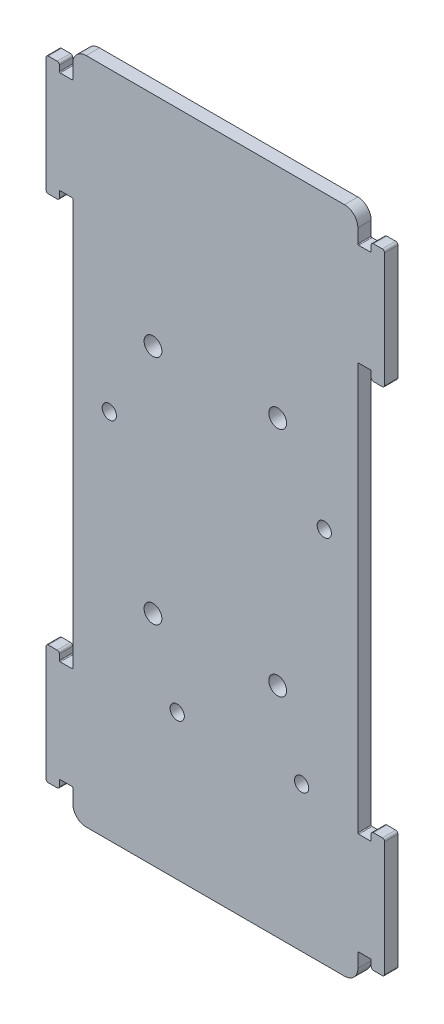
from build123d import *

# Parameters (mm, degrees)
EXTRUDE_1_DEPTH     = 1.5
CUT_EXTRUDE_1_REACH = 5
SKETCH_2_R          = 1.6
SKETCH_3_R          = 2
CUT_EXTRUDE_2_DEPTH = 10


with BuildPart() as part:
    # 草图1 → 凸台-拉伸1 (new body, symmetric)
    with BuildSketch(Plane.XY):
        with BuildLine():
            Line((32.2, 68.7), (34.8, 68.7))
            ThreePointArc((34.8, 68.7), (34.941421356, 68.758578644), (35, 68.9))
            Line((35, 68.9), (35, 70.15))
            ThreePointArc((35, 70.15), (35.146446609, 70.503553391), (35.5, 70.65))
            Line((35.5, 70.65), (37.5, 70.65))
            ThreePointArc((37.5, 70.65), (37.853553391, 70.503553391), (38, 70.15))
            Line((38, 70.15), (38, 44.35))
            ThreePointArc((38, 44.35), (37.853553391, 43.996446609), (37.5, 43.85))
            Line((37.5, 43.85), (35.5, 43.85))
            ThreePointArc((35.5, 43.85), (35.146446609, 43.996446609), (35, 44.35))
            Line((35, 44.35), (35, 45.6))
            ThreePointArc((35, 45.6), (34.941421356, 45.741421356), (34.8, 45.8))
            Line((34.8, 45.8), (32.2, 45.8))
            ThreePointArc((32.2, 45.8), (32.058578644, 45.741421356), (32, 45.6))
            Line((32, 45.6), (32, -45.6))
            ThreePointArc((32, -45.6), (32.058578644, -45.741421356), (32.2, -45.8))
            Line((32.2, -45.8), (34.8, -45.8))
            ThreePointArc((34.8, -45.8), (34.941421356, -45.741421356), (35, -45.6))
            Line((35, -45.6), (35, -44.35))
            ThreePointArc((35, -44.35), (35.146446609, -43.996446609), (35.5, -43.85))
            Line((35.5, -43.85), (37.5, -43.85))
            ThreePointArc((37.5, -43.85), (37.853553391, -43.996446609), (38, -44.35))
            Line((38, -44.35), (38, -70.15))
            ThreePointArc((38, -70.15), (37.853553391, -70.503553391), (37.5, -70.65))
            Line((37.5, -70.65), (35.5, -70.65))
            ThreePointArc((35.5, -70.65), (35.146446609, -70.503553391), (35, -70.15))
            Line((35, -70.15), (35, -68.9))
            ThreePointArc((35, -68.9), (34.941421356, -68.758578644), (34.8, -68.7))
            Line((34.8, -68.7), (32.2, -68.7))
            ThreePointArc((32.2, -68.7), (32.058578644, -68.758578644), (32, -68.9))
            Line((32, -68.9), (32, -72))
            ThreePointArc((32, -72), (31.121320344, -74.121320344), (29, -75))
            Line((29, -75), (-29, -75))
            ThreePointArc((-29, -75), (-31.121320344, -74.121320344), (-32, -72))
            Line((-32, -72), (-32, -68.9))
            ThreePointArc((-32, -68.9), (-32.058578644, -68.758578644), (-32.2, -68.7))
            Line((-32.2, -68.7), (-34.8, -68.7))
            ThreePointArc((-34.8, -68.7), (-34.941421356, -68.758578644), (-35, -68.9))
            Line((-35, -68.9), (-35, -70.15))
            ThreePointArc((-35, -70.15), (-35.146446609, -70.503553391), (-35.5, -70.65))
            Line((-35.5, -70.65), (-37.5, -70.65))
            ThreePointArc((-37.5, -70.65), (-37.853553391, -70.503553391), (-38, -70.15))
            Line((-38, -70.15), (-38, -44.35))
            ThreePointArc((-38, -44.35), (-37.853553391, -43.996446609), (-37.5, -43.85))
            Line((-37.5, -43.85), (-35.5, -43.85))
            ThreePointArc((-35.5, -43.85), (-35.146446609, -43.996446609), (-35, -44.35))
            Line((-35, -44.35), (-35, -45.6))
            ThreePointArc((-35, -45.6), (-34.941421356, -45.741421356), (-34.8, -45.8))
            Line((-34.8, -45.8), (-32.2, -45.8))
            ThreePointArc((-32.2, -45.8), (-32.058578644, -45.741421356), (-32, -45.6))
            Line((-32, -45.6), (-32, 45.6))
            ThreePointArc((-32, 45.6), (-32.058578644, 45.741421356), (-32.2, 45.8))
            Line((-32.2, 45.8), (-34.8, 45.8))
            ThreePointArc((-34.8, 45.8), (-34.941421356, 45.741421356), (-35, 45.6))
            Line((-35, 45.6), (-35, 44.35))
            ThreePointArc((-35, 44.35), (-35.146446609, 43.996446609), (-35.5, 43.85))
            Line((-35.5, 43.85), (-37.5, 43.85))
            ThreePointArc((-37.5, 43.85), (-37.853553391, 43.996446609), (-38, 44.35))
            Line((-38, 44.35), (-38, 70.15))
            ThreePointArc((-38, 70.15), (-37.853553391, 70.503553391), (-37.5, 70.65))
            Line((-37.5, 70.65), (-35.5, 70.65))
            ThreePointArc((-35.5, 70.65), (-35.146446609, 70.503553391), (-35, 70.15))
            Line((-35, 70.15), (-35, 68.9))
            ThreePointArc((-35, 68.9), (-34.941421356, 68.758578644), (-34.8, 68.7))
            Line((-34.8, 68.7), (-32.2, 68.7))
            ThreePointArc((-32.2, 68.7), (-32.058578644, 68.758578644), (-32, 68.9))
            Line((-32, 68.9), (-32, 72))
            ThreePointArc((-32, 72), (-31.121320344, 74.121320344), (-29, 75))
            Line((-29, 75), (29, 75))
            ThreePointArc((29, 75), (31.121320344, 74.121320344), (32, 72))
            Line((32, 72), (32, 68.9))
            ThreePointArc((32, 68.9), (32.058578644, 68.758578644), (32.2, 68.7))
        make_face()
    extrude(amount=EXTRUDE_1_DEPTH, both=True)

    # 草图2 → 切除-拉伸1 (cut, up to next)
    with BuildSketch(Plane(origin=(0, 0, -1.5), x_dir=(-1, 0, 0), z_dir=(0, 0, -1)), mode=Mode.PRIVATE) as cut_extrude_1_sk1:
        with Locations((23.8, 8.34)):
            Circle(SKETCH_2_R)
    cut_extrude_1_tool1 = extrude(cut_extrude_1_sk1.sketch, amount=-CUT_EXTRUDE_1_REACH, mode=Mode.PRIVATE) & part.part
    add(cut_extrude_1_tool1.solids().sort_by_distance((-23.8, 8.34, -1.5))[0], mode=Mode.SUBTRACT)
    # 草图2 → 切除-拉伸1 (cut, up to next)
    with BuildSketch(Plane(origin=(0, 0, -1.5), x_dir=(-1, 0, 0), z_dir=(0, 0, -1)), mode=Mode.PRIVATE) as cut_extrude_1_sk2:
        with Locations((8.56, -42.46)):
            Circle(SKETCH_2_R)
    cut_extrude_1_tool2 = extrude(cut_extrude_1_sk2.sketch, amount=-CUT_EXTRUDE_1_REACH, mode=Mode.PRIVATE) & part.part
    add(cut_extrude_1_tool2.solids().sort_by_distance((-8.56, -42.46, -1.5))[0], mode=Mode.SUBTRACT)
    # 草图2 → 切除-拉伸1 (cut, up to next)
    with BuildSketch(Plane(origin=(0, 0, -1.5), x_dir=(-1, 0, 0), z_dir=(0, 0, -1)), mode=Mode.PRIVATE) as cut_extrude_1_sk3:
        with Locations((-19.38, -42.46)):
            Circle(SKETCH_2_R)
    cut_extrude_1_tool3 = extrude(cut_extrude_1_sk3.sketch, amount=-CUT_EXTRUDE_1_REACH, mode=Mode.PRIVATE) & part.part
    add(cut_extrude_1_tool3.solids().sort_by_distance((19.38, -42.46, -1.5))[0], mode=Mode.SUBTRACT)
    # 草图2 → 切除-拉伸1 (cut, up to next)
    with BuildSketch(Plane(origin=(0, 0, -1.5), x_dir=(-1, 0, 0), z_dir=(0, 0, -1)), mode=Mode.PRIVATE) as cut_extrude_1_sk4:
        with Locations((-24.46, 9.61)):
            Circle(SKETCH_2_R)
    cut_extrude_1_tool4 = extrude(cut_extrude_1_sk4.sketch, amount=-CUT_EXTRUDE_1_REACH, mode=Mode.PRIVATE) & part.part
    add(cut_extrude_1_tool4.solids().sort_by_distance((24.46, 9.61, -1.5))[0], mode=Mode.SUBTRACT)

    # 草图3 → 切除-拉伸2 (cut)
    with BuildSketch(Plane.XY.offset(1.5)):
        with Locations((14, 26)):
            Circle(SKETCH_3_R)
        with Locations((14, -26)):
            Circle(SKETCH_3_R)
        with Locations((-14, 26)):
            Circle(SKETCH_3_R)
        with Locations((-14, -26)):
            Circle(SKETCH_3_R)
    extrude(amount=-CUT_EXTRUDE_2_DEPTH, mode=Mode.SUBTRACT)


solid = part.part
